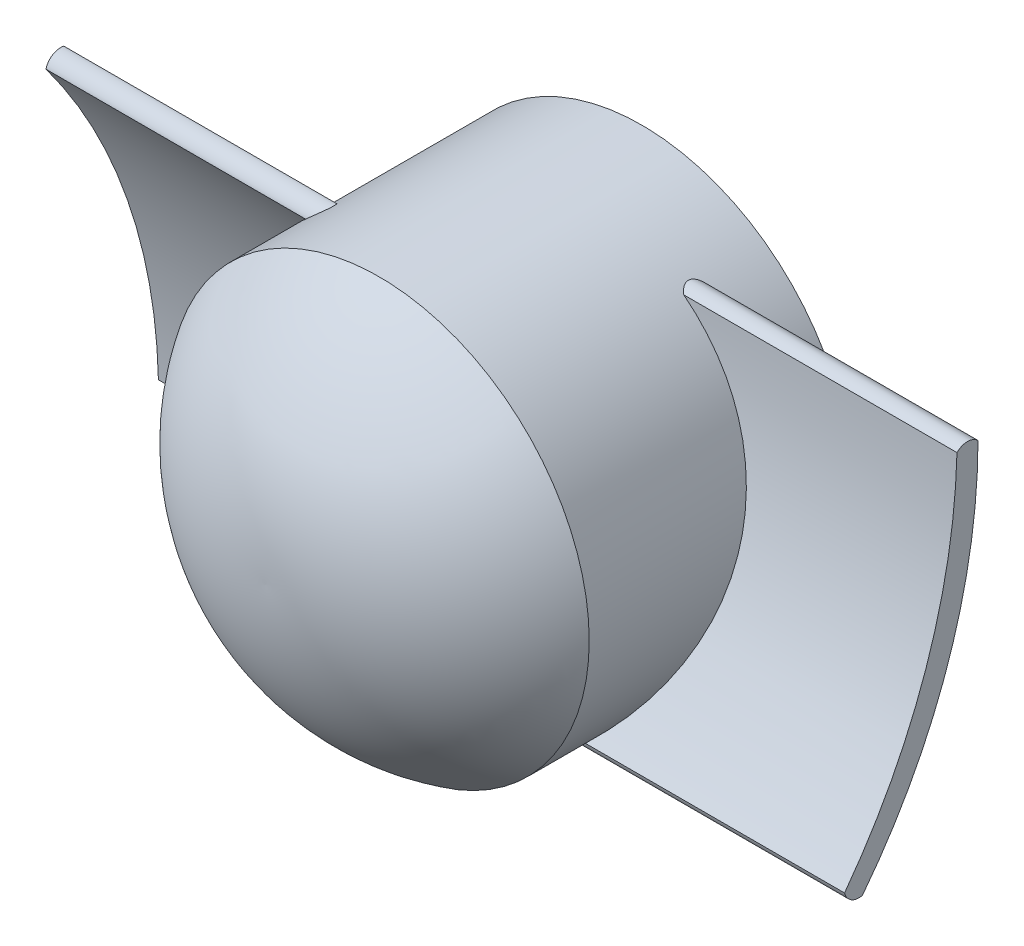
from build123d import *

# Parameters (mm, degrees)
SKETCH1_R      = 20
EXTRUDE1_DEPTH = 25
EXTRUDE2_DEPTH = 38
EXTRUDE3_DEPTH = 38


with BuildPart() as part:
    # Sketch1 → Extrude1 (new body)
    with BuildSketch(Plane.XY):
        Circle(SKETCH1_R)
    extrude(amount=EXTRUDE1_DEPTH)

    # Sketch2 → Revolve1 (revolve)
    with BuildSketch(Plane(origin=(0, 0, 0), x_dir=(0, 0, -1), z_dir=(1, 0, 0))):
        with BuildLine():
            Line((-25, 0), (-35.80749354, 0))
            ThreePointArc((-35.80749354, 0), (-33.08089551, 11.446663385), (-25, 20))
            Line((-25, 20), (-25, 0))
        make_face()
    revolve(axis=Axis((0, 0, 25), (0, 0, 1)))

    # Sketch3 → Extrude2 (add)
    with BuildSketch(Plane(origin=(0, 0, 0), x_dir=(0, 0, -1), z_dir=(1, 0, 0))):
        with BuildLine():
            ThreePointArc((-17, -16), (-8.838692689, -0.914824388), (-6, 16))
            ThreePointArc((-6, 16), (-7, 16.414213562), (-8, 16))
            ThreePointArc((-8, 16), (-10.94657476, -0.304222576), (-18.7, -14.946434625))
            ThreePointArc((-18.7, -14.946434625), (-18.068200534, -15.82529884), (-17, -16))
        make_face()
    extrude(amount=EXTRUDE2_DEPTH)

    # Sketch4 → Extrude3 (add)
    with BuildSketch(Plane(origin=(0, 0, 0), x_dir=(0, 0, -1), z_dir=(1, 0, 0))):
        with BuildLine():
            ThreePointArc((-8, -16), (-7, -16.312065741), (-6, -16))
            ThreePointArc((-6, -16), (-8.838692689, 0.914824388), (-17, 16))
            ThreePointArc((-17, 16), (-18.068200534, 15.82529884), (-18.7, 14.946434625))
            ThreePointArc((-18.7, 14.946434625), (-10.94657476, 0.304222576), (-8, -16))
        make_face()
    extrude(amount=-EXTRUDE3_DEPTH)


solid = part.part
